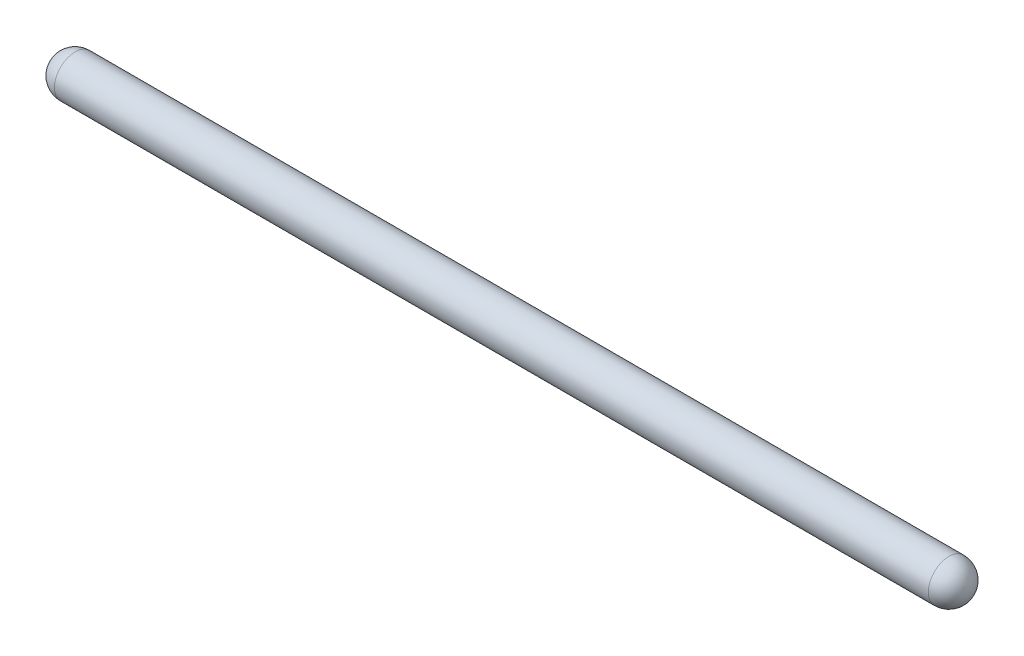
from build123d import *


with BuildPart() as part:
    # Sketch2 → Revolve2 (revolve)
    with BuildSketch(Plane.XY):
        with BuildLine():
            Line((0, 1.5), (63.5, 1.5))
            ThreePointArc((63.5, 1.5), (64.560660172, 1.060660172), (65, 0))
            Line((65, 0), (-1.5, 0))
            ThreePointArc((-1.5, 0), (-1.060660172, 1.060660172), (0, 1.5))
        make_face()
    revolve(axis=Axis((0, 0, 0), (1, 0, 0)))


solid = part.part
